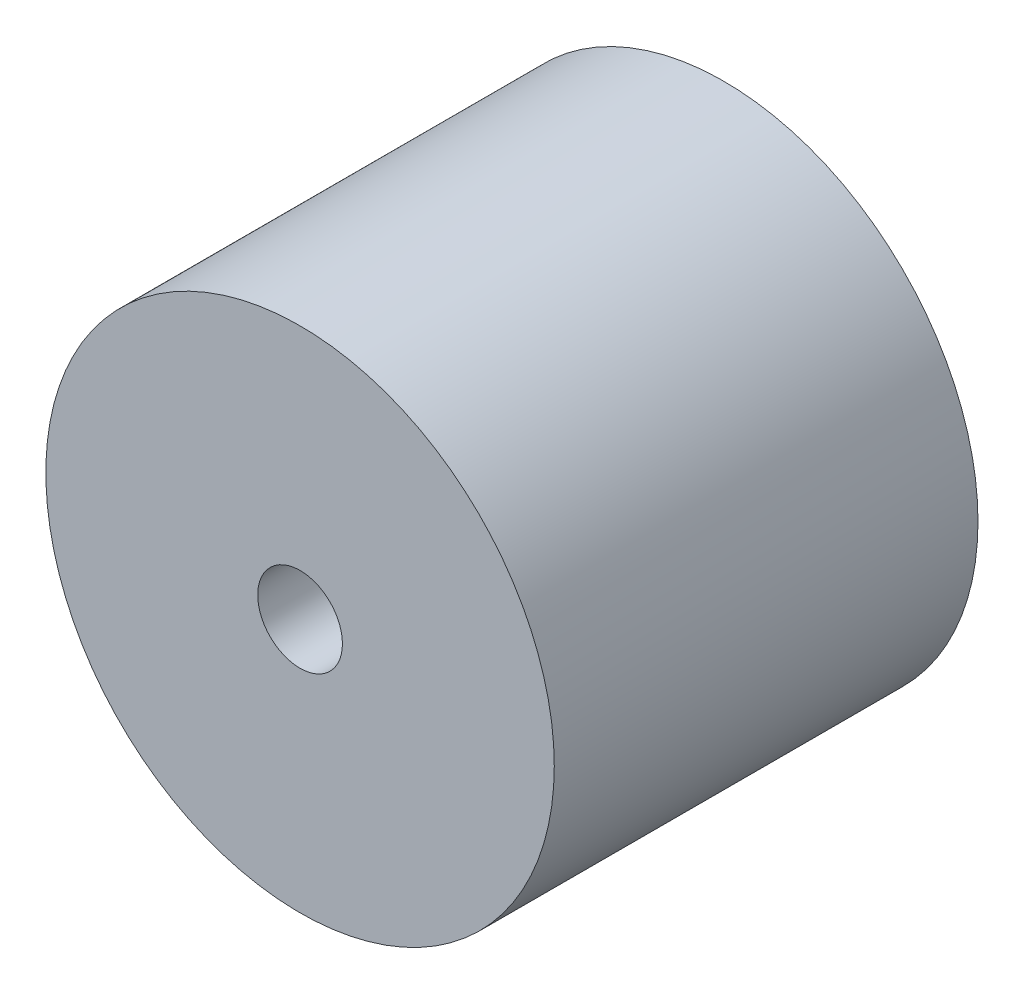
from build123d import *

# Parameters (mm, degrees)
SKETCH1_R           = 18
SKETCH1_R_2         = 3
BOSS_EXTRUDE1_DEPTH = 15


with BuildPart() as part:
    # Sketch1 → Boss-Extrude1 (new body, symmetric)
    with BuildSketch(Plane.XY):
        Circle(SKETCH1_R)
        Circle(SKETCH1_R_2, mode=Mode.SUBTRACT)
    extrude(amount=BOSS_EXTRUDE1_DEPTH, both=True)


solid = part.part
